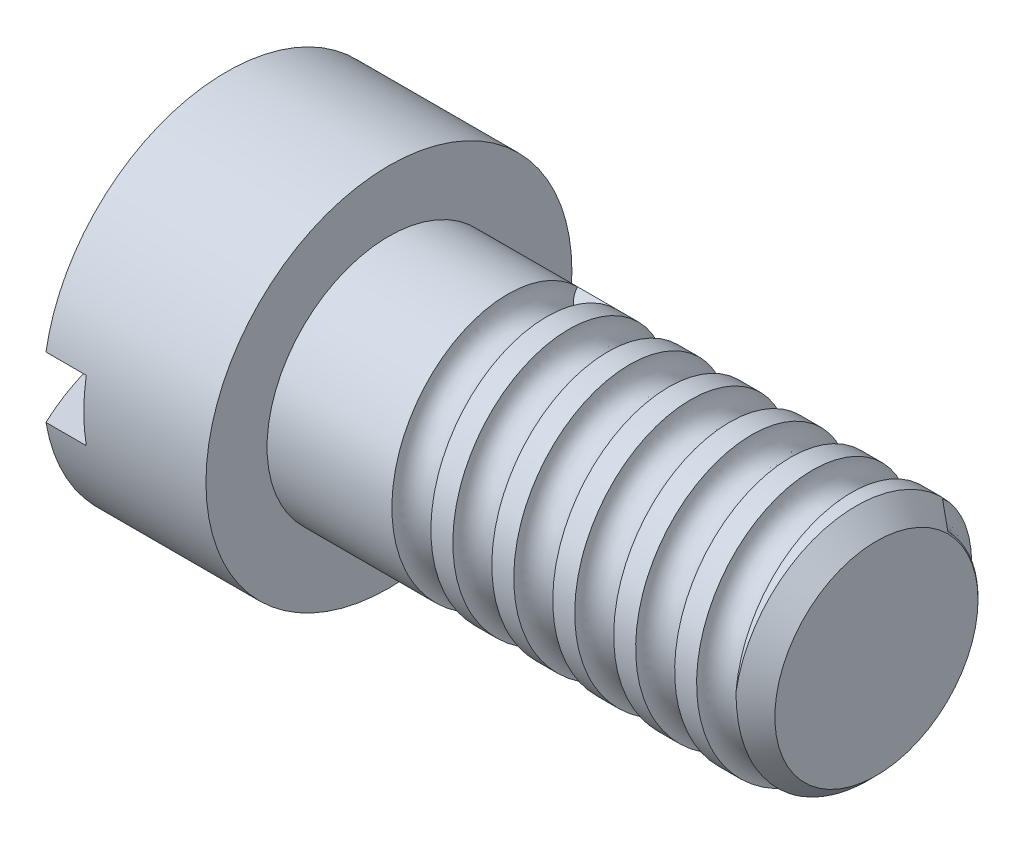
from build123d import *

# Parameters (mm, degrees)
SKETCH3_W              = 5.208459608
SKETCH3_H              = 2.38125
CUT_EXTRUDE1_DEPTH     = 33.859919234
CHAMFER1_SIZE          = 0.79375
CUT_SWEEP1_PITCH       = 2.38125
CUT_SWEEP1_HEIGHT      = 14.2875
CUT_SWEEP1_RADIUS      = 4.7625
CUT_SWEEP1_START_ANGLE = -45
SKETCH15_R             = 0.762


with BuildPart() as part:
    # Sketch2 → Revolve1 (revolve)
    with BuildSketch(Plane.XY, mode=Mode.PRIVATE) as revolve1_sk:
        with BuildLine():
            Line((0, 0), (0, 4.7625))
            Line((0, 4.7625), (-19.05, 4.7625))
            Line((-19.05, 4.7625), (-19.05, 7.1501))
            Line((-19.05, 7.1501), (-25.4, 7.1501))
            ThreePointArc((-25.4, 7.1501), (-26.483097371, 4.247979145), (-27.0002, 1.1938))
            Line((-27.0002, 1.1938), (-27.0002, 0))
            Line((-27.0002, 0), (-23.8252, 0))
            Line((-23.8252, 0), (0, 0))
        make_face()
    revolve(revolve1_sk.sketch.rotate(Axis((11.818555241, 0, 0), (-1, 0, 0)), 90), axis=Axis((11.818555241, 0, 0), (-1, 0, 0)))

    # Sketch3 → Cut-Extrude1 (cut, through all)
    with BuildSketch(Plane.XY.offset(10.16)):
        with Locations((-26.429429804, 0)):
            Rectangle(SKETCH3_W, SKETCH3_H)
    extrude(amount=-CUT_EXTRUDE1_DEPTH, mode=Mode.SUBTRACT)

    # Chamfer1
    chamfer1_edges = [part.edges().sort_by_distance(p)[0] for p in [
        (0, 0, 4.7625),
    ]]
    chamfer(chamfer1_edges, length=CHAMFER1_SIZE)

    # Cut-Sweep1: sweep along a helix
    with BuildLine() as cut_sweep1_path:
        add(Helix(CUT_SWEEP1_PITCH, CUT_SWEEP1_HEIGHT, CUT_SWEEP1_RADIUS, center=(0, 0, 0), direction=(-1, 0, 0), mode=Mode.PRIVATE).rotate(Axis((0, 0, 0), (-1, 0, 0)), CUT_SWEEP1_START_ANGLE))
    # Sketch15 → Cut-Sweep1 (sweep, cut)
    with BuildSketch(Plane(origin=(0, 0, 0), x_dir=(1, 0, 0), z_dir=(0, 0.7071067811865462, 0.7071067811865488))):
        with Locations((0, 4.780536991)):
            Circle(SKETCH15_R)
    sweep(path=cut_sweep1_path.line, is_frenet=True, mode=Mode.SUBTRACT)


solid = part.part
